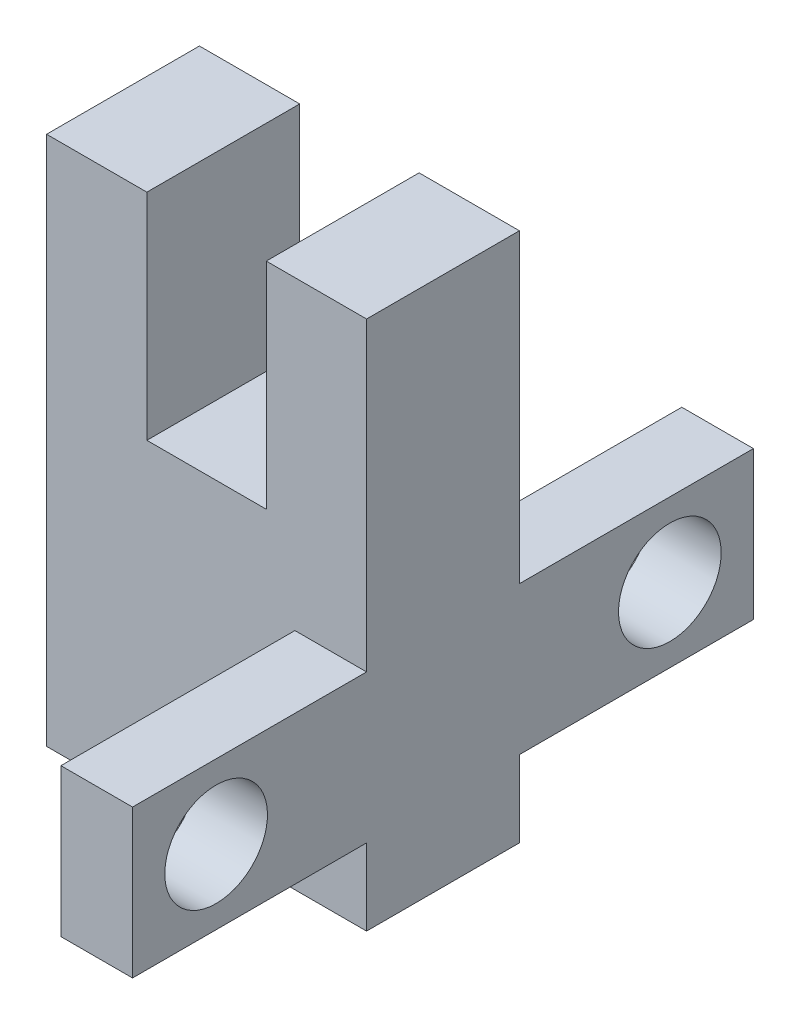
from build123d import *

# Parameters (mm, degrees)
SKETCH_1_W          = 13.4
SKETCH_1_H          = 22.2
EXTRUDE_1_DEPTH     = 6.4
SKETCH_2_W          = 5
SKETCH_2_H          = 9
CUT_EXTRUDE_1_DEPTH = 6.4
SKETCH_3_W          = 3
SKETCH_3_H          = 6.2
EXTRUDE_2_DEPTH     = 9.8
SKETCH_4_R          = 2.15
CUT_EXTRUDE_2_DEPTH = 9.8


with BuildPart() as part:
    # 草图1 → 凸台-拉伸1 (new body)
    with BuildSketch(Plane.XY):
        with Locations((6.7, 11.1)):
            Rectangle(SKETCH_1_W, SKETCH_1_H)
    extrude(amount=EXTRUDE_1_DEPTH)

    # 草图2 → 切除-拉伸1 (cut)
    with BuildSketch(Plane.XY.offset(6.4)):
        with Locations((6.7, 17.7)):
            Rectangle(SKETCH_2_W, SKETCH_2_H)
    extrude(amount=-CUT_EXTRUDE_1_DEPTH, mode=Mode.SUBTRACT)

    # 草图3 → 凸台-拉伸2 (add)
    with BuildSketch(Plane.XY.offset(6.4)):
        with Locations((11.9, 6.3)):
            Rectangle(SKETCH_3_W, SKETCH_3_H)
    extrude_2 = extrude(amount=EXTRUDE_2_DEPTH)

    # 镜向1: 凸台-拉伸2 across plane
    add(extrude_2.mirror(Plane(origin=(0, 0, 3.2), x_dir=(1, 0, 0), z_dir=(0, 0, -1))))

    # 草图4 → 切除-拉伸2 (cut)
    with BuildSketch(Plane.ZY.offset(-10.4)):
        with Locations((-6.3, 6.3)):
            Circle(SKETCH_4_R)
        with Locations((12.7, 6.3)):
            Circle(SKETCH_4_R)
    extrude(amount=-CUT_EXTRUDE_2_DEPTH, mode=Mode.SUBTRACT)


solid = part.part
